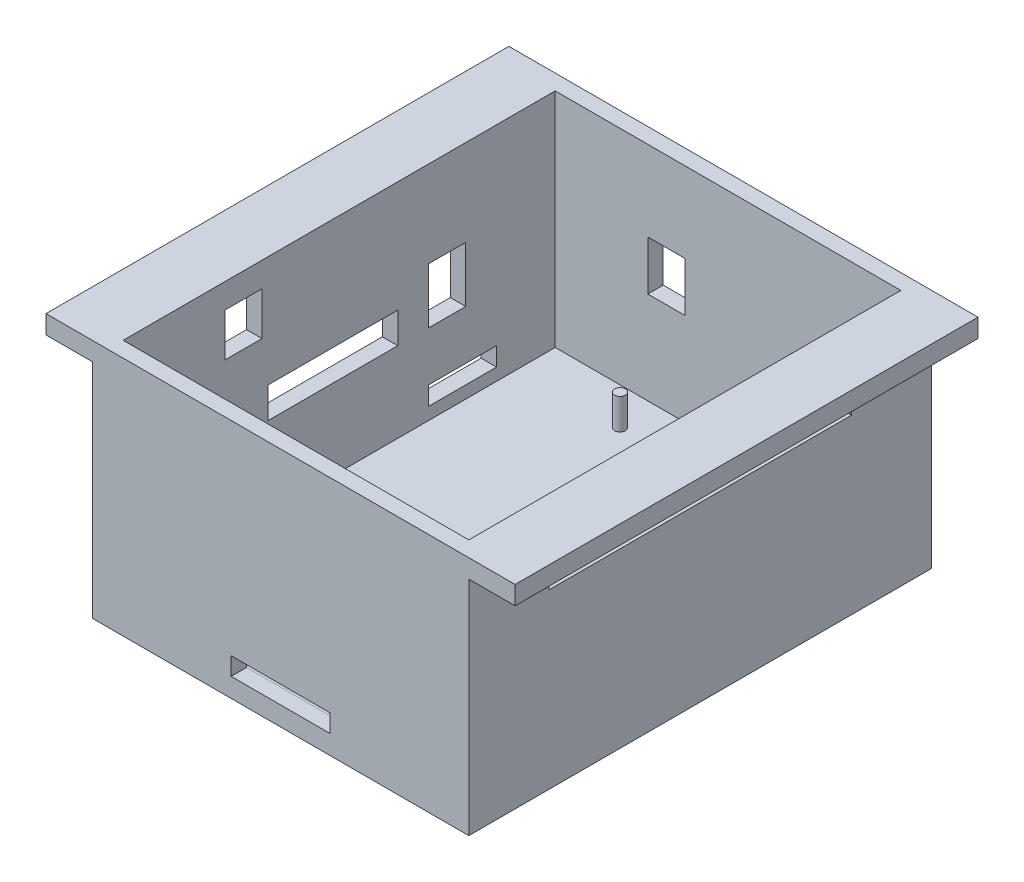
from build123d import *

# Parameters (mm, degrees)
BOSS_EXTRUDE1_DEPTH = 75
SKETCH4_W           = 56
SKETCH4_H           = 70
CUT_EXTRUDE1_DEPTH  = 36
SKETCH21_R          = 0.875
BOSS_EXTRUDE3_DEPTH = 5
CUT_EXTRUDE2_REACH  = 77
SKETCH23_W          = 11.9
SKETCH23_H          = 2.9
CUT_EXTRUDE3_REACH  = 70.5
SKETCH24_W          = 11
SKETCH24_H          = 3
CUT_EXTRUDE4_REACH  = 70.5
SKETCH25_W          = 7
SKETCH25_H          = 2
CUT_EXTRUDE5_REACH  = 70.5
SKETCH26_W          = 7.2
SKETCH26_H          = 2
CUT_EXTRUDE6_REACH  = 77
SKETCH27_W          = 16
SKETCH27_H          = 2.9
CUT_EXTRUDE7_REACH  = 70.5
SKETCH28_W          = 6
SKETCH28_H          = 9
CUT_EXTRUDE8_REACH  = 70.5
SKETCH29_W          = 21
SKETCH29_H          = 5
CUT_EXTRUDE9_REACH  = 77
SKETCH30_W          = 6
SKETCH30_H          = 8
CUT_EXTRUDE10_REACH = 70.5
SKETCH31_W          = 49
SKETCH31_H          = 7
CUT_EXTRUDE11_REACH = 70.5
SKETCH32_W          = 6
SKETCH32_H          = 7


with BuildPart() as part:
    # Sketch1 → Boss-Extrude1 (new body)
    with BuildSketch(Plane.XY):
        Polygon((-37.771390637, 7.690116692), (-37.771390637, 10.690116692), (38.228609363, 10.690116692), (38.228609363, 7.690116692), (30.728609363, 7.690116692), (30.728609363, -28.309883308), (-30.271390637, -28.309883308), (-30.271390637, 7.690116692), align=None)
    extrude(amount=BOSS_EXTRUDE1_DEPTH)

    # Sketch4 → Cut-Extrude1 (cut)
    with BuildSketch(Plane(origin=(0, 10.690116692, 0), x_dir=(1, 0, 0), z_dir=(0, 1, 0))):
        with Locations((0.228609363, -37.5)):
            Rectangle(SKETCH4_W, SKETCH4_H)
    extrude(amount=-CUT_EXTRUDE1_DEPTH, mode=Mode.SUBTRACT)

    # Sketch21 → Boss-Extrude3 (add)
    with BuildSketch(Plane(origin=(0, -25.309883308, 0), x_dir=(1, 0, 0), z_dir=(0, 1, 0))):
        with Locations((-11.271390637, -8.5)):
            Circle(SKETCH21_R)
        with Locations((11.728609363, -8.5)):
            Circle(SKETCH21_R)
        with Locations((-11.271390637, -66.5)):
            Circle(SKETCH21_R)
        with Locations((11.728609363, -66.5)):
            Circle(SKETCH21_R)
    extrude(amount=BOSS_EXTRUDE3_DEPTH)

    # Sketch23 → Cut-Extrude2 (cut, up to next)
    with BuildSketch(Plane(origin=(0, 0, 0), x_dir=(-1, 0, 0), z_dir=(0, 0, -1)), mode=Mode.PRIVATE) as cut_extrude2_sk1:
        with Locations((-2.078609363, -23.759883308)):
            Rectangle(SKETCH23_W, SKETCH23_H)
    cut_extrude2_tool1 = extrude(cut_extrude2_sk1.sketch, amount=-CUT_EXTRUDE2_REACH, mode=Mode.PRIVATE) & part.part
    add(cut_extrude2_tool1.solids().sort_by_distance((2.078609, -23.759883, 0))[0], mode=Mode.SUBTRACT)

    # Sketch24 → Cut-Extrude3 (cut, up to next)
    with BuildSketch(Plane.ZY.offset(30.271390637), mode=Mode.PRIVATE) as cut_extrude3_sk1:
        with Locations((17.5, -21.809883308)):
            Rectangle(SKETCH24_W, SKETCH24_H)
    cut_extrude3_tool1 = extrude(cut_extrude3_sk1.sketch, amount=-CUT_EXTRUDE3_REACH, mode=Mode.PRIVATE) & part.part
    add(cut_extrude3_tool1.solids().sort_by_distance((-30.271391, -21.809883, 17.5))[0], mode=Mode.SUBTRACT)

    # Sketch25 → Cut-Extrude4 (cut, up to next)
    with BuildSketch(Plane.ZY.offset(30.271390637), mode=Mode.PRIVATE) as cut_extrude4_sk1:
        with Locations((46.4, -22.309883308)):
            Rectangle(SKETCH25_W, SKETCH25_H)
    cut_extrude4_tool1 = extrude(cut_extrude4_sk1.sketch, amount=-CUT_EXTRUDE4_REACH, mode=Mode.PRIVATE) & part.part
    add(cut_extrude4_tool1.solids().sort_by_distance((-30.271391, -22.309883, 46.4))[0], mode=Mode.SUBTRACT)

    # Sketch26 → Cut-Extrude5 (cut, up to next)
    with BuildSketch(Plane.ZY.offset(30.271390637), mode=Mode.PRIVATE) as cut_extrude5_sk1:
        with Locations((59.4, -22.309883308)):
            Rectangle(SKETCH26_W, SKETCH26_H)
    cut_extrude5_tool1 = extrude(cut_extrude5_sk1.sketch, amount=-CUT_EXTRUDE5_REACH, mode=Mode.PRIVATE) & part.part
    add(cut_extrude5_tool1.solids().sort_by_distance((-30.271391, -22.309883, 59.4))[0], mode=Mode.SUBTRACT)

    # Sketch27 → Cut-Extrude6 (cut, up to next)
    with BuildSketch(Plane.XY.offset(75), mode=Mode.PRIVATE) as cut_extrude6_sk1:
        with Locations((0.228609363, -23.759883308)):
            Rectangle(SKETCH27_W, SKETCH27_H)
    cut_extrude6_tool1 = extrude(cut_extrude6_sk1.sketch, amount=-CUT_EXTRUDE6_REACH, mode=Mode.PRIVATE) & part.part
    add(cut_extrude6_tool1.solids().sort_by_distance((0.228609, -23.759883, 75))[0], mode=Mode.SUBTRACT)

    # Sketch28 → Cut-Extrude7 (cut, up to next)
    with BuildSketch(Plane.ZY.offset(30.271390637), mode=Mode.PRIVATE) as cut_extrude7_sk1:
        with Locations((20, -7.809883308)):
            Rectangle(SKETCH28_W, SKETCH28_H)
    cut_extrude7_tool1 = extrude(cut_extrude7_sk1.sketch, amount=-CUT_EXTRUDE7_REACH, mode=Mode.PRIVATE) & part.part
    add(cut_extrude7_tool1.solids().sort_by_distance((-30.271391, -7.809883, 20))[0], mode=Mode.SUBTRACT)

    # Sketch29 → Cut-Extrude8 (cut, up to next)
    with BuildSketch(Plane.ZY.offset(30.271390637), mode=Mode.PRIVATE) as cut_extrude8_sk1:
        with Locations((38.5, -9.809883308)):
            Rectangle(SKETCH29_W, SKETCH29_H)
    cut_extrude8_tool1 = extrude(cut_extrude8_sk1.sketch, amount=-CUT_EXTRUDE8_REACH, mode=Mode.PRIVATE) & part.part
    add(cut_extrude8_tool1.solids().sort_by_distance((-30.271391, -9.809883, 38.5))[0], mode=Mode.SUBTRACT)

    # Sketch30 → Cut-Extrude9 (cut, up to next)
    with BuildSketch(Plane(origin=(0, 0, 0), x_dir=(-1, 0, 0), z_dir=(0, 0, -1)), mode=Mode.PRIVATE) as cut_extrude9_sk1:
        with Locations((9.771390637, -6.309883308)):
            Rectangle(SKETCH30_W, SKETCH30_H)
    cut_extrude9_tool1 = extrude(cut_extrude9_sk1.sketch, amount=-CUT_EXTRUDE9_REACH, mode=Mode.PRIVATE) & part.part
    add(cut_extrude9_tool1.solids().sort_by_distance((-9.771391, -6.309883, 0))[0], mode=Mode.SUBTRACT)

    # Sketch31 → Cut-Extrude10 (cut, up to next)
    with BuildSketch(Plane(origin=(30.728609363, 0, 0), x_dir=(0, 0, -1), z_dir=(1, 0, 0)), mode=Mode.PRIVATE) as cut_extrude10_sk1:
        with Locations((-37.5, 3.190116692)):
            Rectangle(SKETCH31_W, SKETCH31_H)
    cut_extrude10_tool1 = extrude(cut_extrude10_sk1.sketch, amount=-CUT_EXTRUDE10_REACH, mode=Mode.PRIVATE) & part.part
    add(cut_extrude10_tool1.solids().sort_by_distance((30.728609, 3.190117, 37.5))[0], mode=Mode.SUBTRACT)

    # Sketch32 → Cut-Extrude11 (cut, up to next)
    with BuildSketch(Plane.ZY.offset(30.271390637), mode=Mode.PRIVATE) as cut_extrude11_sk1:
        with Locations((53, 3.190116692)):
            Rectangle(SKETCH32_W, SKETCH32_H)
    cut_extrude11_tool1 = extrude(cut_extrude11_sk1.sketch, amount=-CUT_EXTRUDE11_REACH, mode=Mode.PRIVATE) & part.part
    add(cut_extrude11_tool1.solids().sort_by_distance((-30.271391, 3.190117, 53))[0], mode=Mode.SUBTRACT)


solid = part.part
